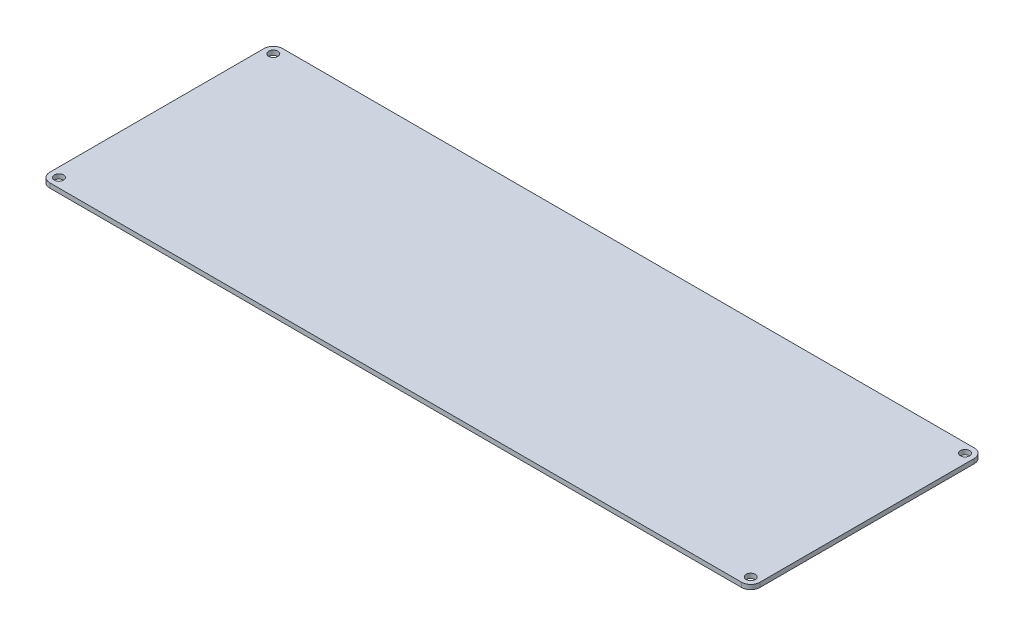
from build123d import *

# Parameters (mm, degrees)
SKETCH1_W           = 490.720000372
SKETCH1_H           = 160.782
SKETCH1_R           = 3.175
BOSS_EXTRUDE1_DEPTH = 3.175
FILLET1_R           = 6.35


with BuildPart() as part:
    # Sketch1 → Boss-Extrude1 (new body)
    with BuildSketch(Plane(origin=(0, 0, 0), x_dir=(1, 0, 0), z_dir=(0, 1, 0))):
        with Locations((88.591461676, 105.906050824)):
            Rectangle(SKETCH1_W, SKETCH1_H)
        with Locations((327.601461862, 179.947050824)):
            Circle(SKETCH1_R, mode=Mode.SUBTRACT)
        with Locations((327.601461862, 31.865050824)):
            Circle(SKETCH1_R, mode=Mode.SUBTRACT)
        with Locations((-150.41853851, 31.865050824)):
            Circle(SKETCH1_R, mode=Mode.SUBTRACT)
        with Locations((-150.41853851, 179.947050824)):
            Circle(SKETCH1_R, mode=Mode.SUBTRACT)
    extrude(amount=-BOSS_EXTRUDE1_DEPTH)

    # Fillet1
    fillet1_edges = [part.edges().sort_by_distance(p)[0] for p in [
        (333.951461862, -1.5875, -25.515050824),
        (-156.76853851, -1.5875, -25.515050824),
        (-156.76853851, -1.5875, -186.297050824),
        (333.951461862, -1.5875, -186.297050824),
    ]]
    fillet(fillet1_edges, radius=FILLET1_R)


solid = part.part
